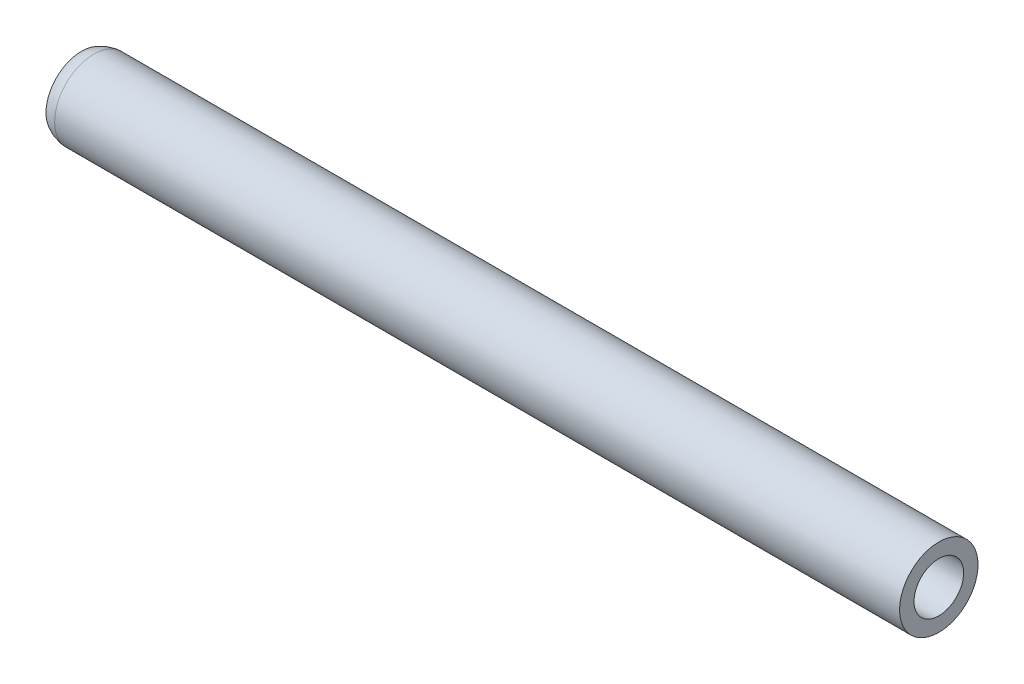
from build123d import *

# Parameters (mm, degrees)
SKETCH1_R                = 16.256
SKETCH1_R_2              = 10.287
BOSS_EXTRUDE1_DEPTH      = 177.8
BOSS_EXTRUDE1_DEPTH_BACK = 177.8


with BuildPart() as part:
    # Sketch1 → Boss-Extrude1 (new body, two sides)
    with BuildSketch(Plane(origin=(0, 0, 0), x_dir=(0, 0, -1), z_dir=(1, 0, 0))) as boss_extrude1_sk:
        Circle(SKETCH1_R)
        Circle(SKETCH1_R_2, mode=Mode.SUBTRACT)
    extrude(amount=BOSS_EXTRUDE1_DEPTH)
    extrude(boss_extrude1_sk.sketch, amount=-BOSS_EXTRUDE1_DEPTH_BACK)

    # Sketch3 → Cut-Revolve1 (revolve, cut)
    with BuildSketch(Plane(origin=(0, 0, 0), x_dir=(1, 0, 0), z_dir=(0, 1, 0))):
        with BuildLine():
            Line((-172.687403521, 16.256), (-177.8, 16.256))
            Line((-177.8, 16.256), (-177.8, 14.732))
            ThreePointArc((-177.8, 14.732), (-175.333861634, 15.79646132), (-172.687403521, 16.256))
        make_face()
    revolve(axis=Axis((-177.8, 0, 0), (1, 0, 0)), mode=Mode.SUBTRACT)


solid = part.part
